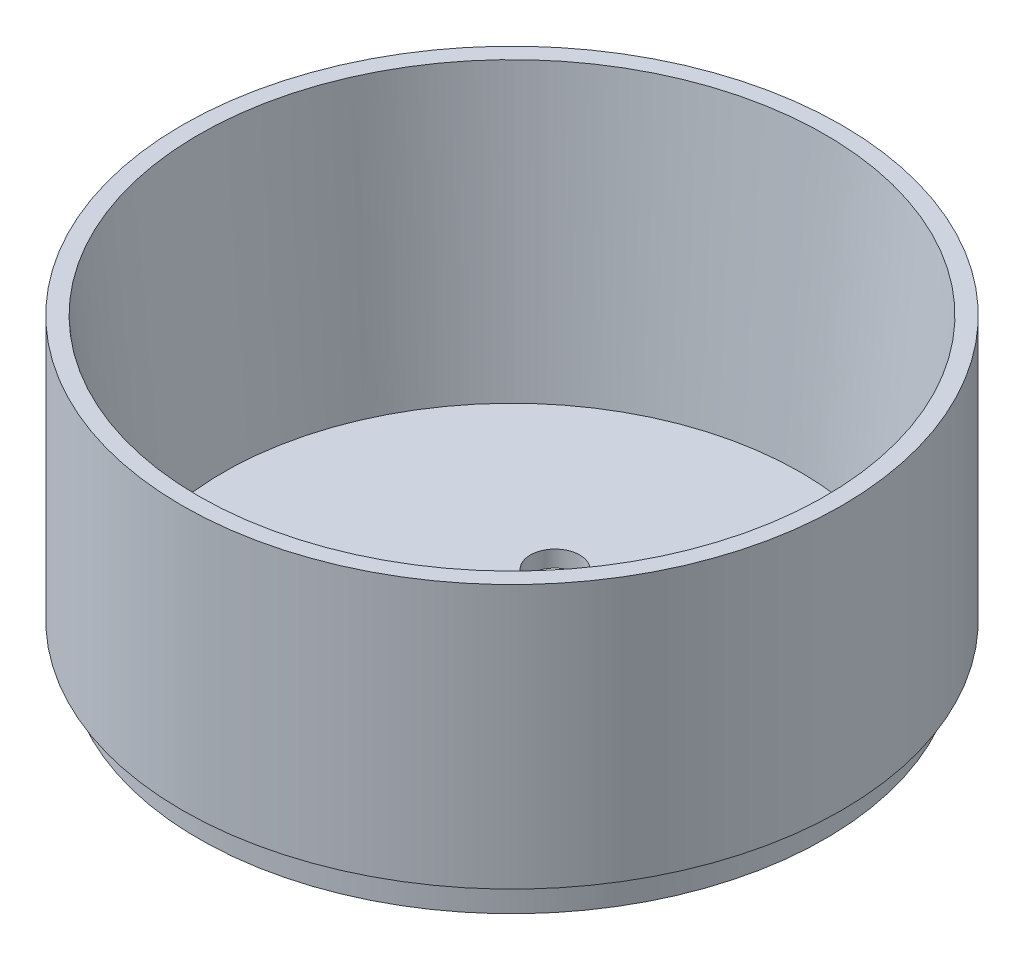
from build123d import *

# Parameters (mm, degrees)
SKETCH1_R           = 63.5
BOSS_EXTRUDE1_DEPTH = 50.8
SKETCH2_R           = 60.325
SKETCH2_R_2         = 57.15
BOSS_EXTRUDE2_DEPTH = 6.35
SKETCH3_R           = 60.325
CUT_EXTRUDE1_DEPTH  = 53.975
CUT_EXTRUDE1_DRAFT  = -5
SKETCH4_R           = 4.7625
CUT_EXTRUDE3_DEPTH  = 3.175


with BuildPart() as part:
    # Sketch1 → Boss-Extrude1 (new body)
    with BuildSketch(Plane(origin=(0, 0, 0), x_dir=(1, 0, 0), z_dir=(0, 1, 0))):
        with Locations(Location((0, 0, 0), (0, 0, 270))):
            Circle(SKETCH1_R)
    extrude(amount=BOSS_EXTRUDE1_DEPTH)

    # Sketch2 → Boss-Extrude2 (add)
    with BuildSketch(Plane.XZ):
        with Locations(Location((0, 0, 0), (0, 0, 270))):
            Circle(SKETCH2_R)
        Circle(SKETCH2_R_2, mode=Mode.SUBTRACT)
        Circle(SKETCH2_R_2)
    extrude(amount=BOSS_EXTRUDE2_DEPTH)


with BuildPart() as cut_extrude1_tool:
    # Sketch3 → Cut-Extrude1 (with draft: the straight prism first)
    with BuildSketch(Plane(origin=(0, 50.8, 0), x_dir=(1, 0, 0), z_dir=(0, 1, 0))):
        with Locations(Location((0, 0, 0), (0, 0, 90))):
            Circle(SKETCH3_R)
    extrude(amount=-CUT_EXTRUDE1_DEPTH)
    # Cut-Extrude1: the draft: its side faces are tilted about the plane it starts from
    cut_extrude1_sides = [cut_extrude1_tool.faces().sort_by_distance(p)[0] for p in [
        (0, 23.8125, 60.325),
    ]]
    draft(cut_extrude1_sides, Plane(origin=(0, 50.8, 0), x_dir=(1, 0, 0), z_dir=(0, 1, 0)), CUT_EXTRUDE1_DRAFT)


with BuildPart() as part_1:
    add(part.part)

    # Cut-Extrude1: cut by cut_extrude1_tool
    add(cut_extrude1_tool.part, mode=Mode.SUBTRACT)

    # Sketch4 → Cut-Extrude3 (cut)
    with BuildSketch(Plane(origin=(0, -3.175, 0), x_dir=(1, 0, 0), z_dir=(0, 1, 0))):
        with Locations(Location((7.487131795, -15.775986934, 0), (0, 0, 270))):
            Circle(SKETCH4_R)
        with Locations(Location((0, 0, 0), (0, 0, 270))):
            Circle(SKETCH4_R)
        with Locations(Location((-7.487131795, 15.775986934, 0), (0, 0, 270))):
            Circle(SKETCH4_R)
    extrude(amount=-CUT_EXTRUDE3_DEPTH, mode=Mode.SUBTRACT)


solid = part_1.part
